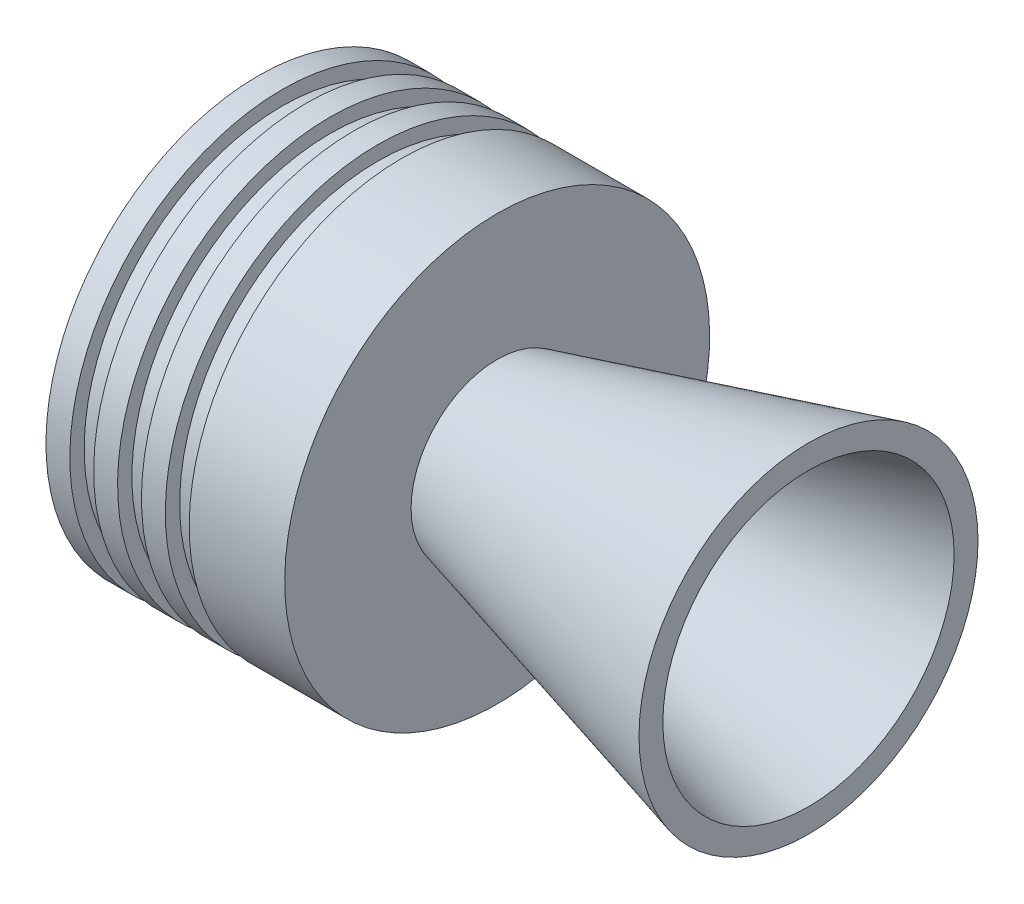
from build123d import *


with BuildPart() as part:
    # Sketch1 → Revolve1 (revolve)
    with BuildSketch(Plane.XY):
        Polygon((-82.105117767, 11.5), (0, 33.5), (0, 38.5), (-76.4, 18.028681698), (-76.4, 44.496311912), (-96.4, 44.496311912), (-96.4, 41.496311912), (-101.4, 41.496311912), (-101.4, 44.496311912), (-106.4, 44.496311912), (-106.4, 41.496311912), (-111.4, 41.496311912), (-111.4, 44.496311912), (-116.4, 44.496311912), (-116.4, 41.496311912), (-121.4, 41.496311912), (-121.4, 44.496311912), (-126.4, 44.496311912), (-126.4, 36.496311912), (-83.105117767, 11.5), align=None)
    revolve(axis=Axis((0, 0, 0), (-1, 0, 0)))

    # Sketch2 → Cut-Revolve1 (revolve, cut)
    with BuildSketch(Plane.XY):
        Polygon((-11.196152423, 0), (-11.196152423, 35.5), (-11.196152423, 56.271944123), (14.531335426, 56.271944123), (14.531335426, 0), align=None)
    revolve(axis=Axis((0, 0, 0), (-1, 0, 0)), mode=Mode.SUBTRACT)


solid = part.part
